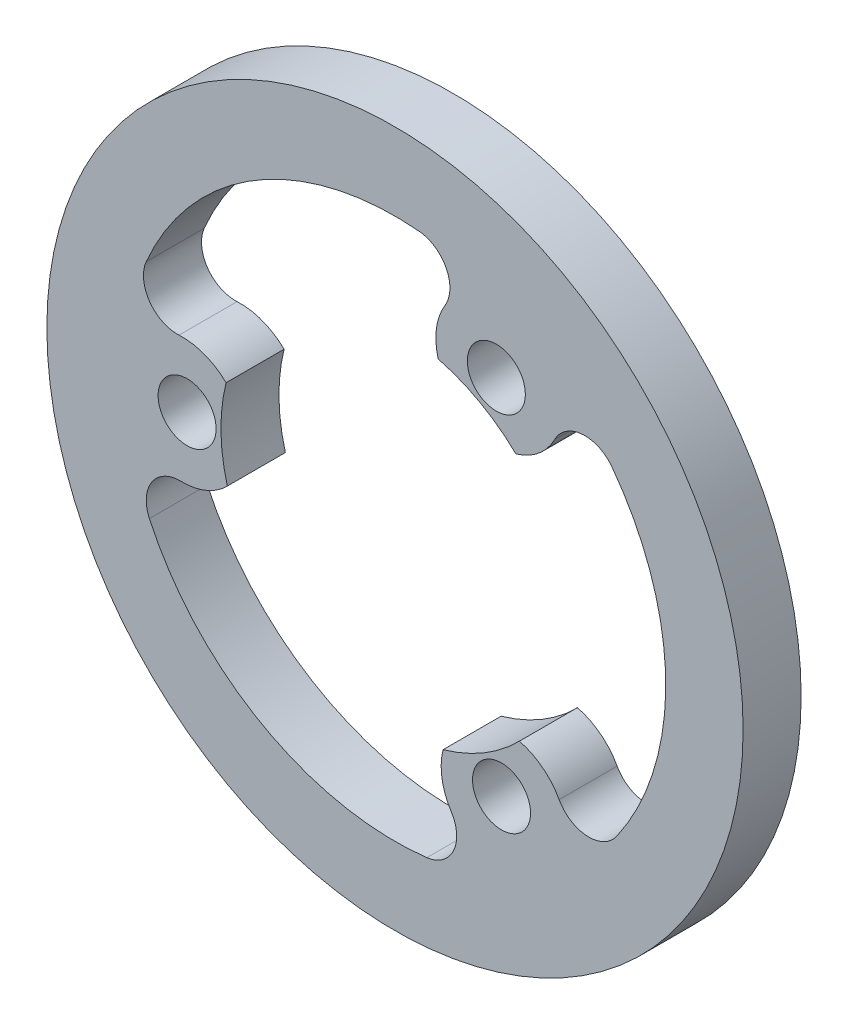
from build123d import *

# Parameters (mm, degrees)
ESQUISSE1_R        = 18
ESQUISSE1_R_2      = 1.5
BOSS_EXTRU_1_DEPTH = 3


with BuildPart() as part:
    # Esquisse1 → Boss.-Extru.1 (new body)
    with BuildSketch(Plane.XY):
        Circle(ESQUISSE1_R)
        with Locations((5.240453276, 9.386167986)):
            Circle(ESQUISSE1_R_2, mode=Mode.SUBTRACT)
        with Locations((5.508433282, -9.231449657)):
            Circle(ESQUISSE1_R_2, mode=Mode.SUBTRACT)
        with Locations((-10.748886558, -0.154718329)):
            Circle(ESQUISSE1_R_2, mode=Mode.SUBTRACT)
        with BuildLine():
            ThreePointArc((2.485564989, -8.649969172), (4.611711585, -7.728655527), (6.432157603, -6.295025701))
            ThreePointArc((6.432157603, -6.295025701), (7.625396258, -6.875738378), (8.487039823, -7.88500349))
            ThreePointArc((8.487039823, -7.88500349), (9.92431211, -8.79166991), (11.453630047, -8.050736534))
            ThreePointArc((11.453630047, -8.050736534), (13.998549936, 0.201493638), (11.217170127, 8.377057619))
            ThreePointArc((11.217170127, 8.377057619), (9.667160345, 9.073667479), (8.256579008, 8.126009358))
            ThreePointArc((8.256579008, 8.126009358), (7.424340898, 7.092362693), (6.248310551, 6.47754701))
            ThreePointArc((6.248310551, 6.47754701), (4.387356231, 7.858187151), (2.235573373, 8.717924736))
            ThreePointArc((2.235573373, 8.717924736), (2.141865976, 10.041656062), (2.58509342, 11.292493835))
            ThreePointArc((2.58509342, 11.292493835), (2.651653429, 12.990541357), (1.245327334, 13.944502853))
            ThreePointArc((1.245327334, 13.944502853), (-7.173773577, 12.022353042), (-12.86332977, 5.525825479))
            ThreePointArc((-12.86332977, 5.525825479), (-12.691606715, 3.835172702), (-11.165620039, 3.087402491))
            ThreePointArc((-11.165620039, 3.087402491), (-9.854336713, 2.883486477), (-8.73387554, 2.172422163))
            ThreePointArc((-8.73387554, 2.172422163), (-8.999067816, -0.129531624), (-8.667730976, -2.422899035))
            ThreePointArc((-8.667730976, -2.422899035), (-9.767262234, -3.165917684), (-11.072133243, -3.407490345))
            ThreePointArc((-11.072133243, -3.407490345), (-12.575965538, -4.198871447), (-12.698957381, -5.893766319))
            ThreePointArc((-12.698957381, -5.893766319), (-6.824776359, -12.22384668), (1.646159643, -13.902883098))
            ThreePointArc((1.646159643, -13.902883098), (3.02444637, -12.90884018), (2.909041031, -11.213411848))
            ThreePointArc((2.909041031, -11.213411848), (2.429995816, -9.97584917), (2.485564989, -8.649969172))
        make_face(mode=Mode.SUBTRACT)
    extrude(amount=BOSS_EXTRU_1_DEPTH)


solid = part.part
